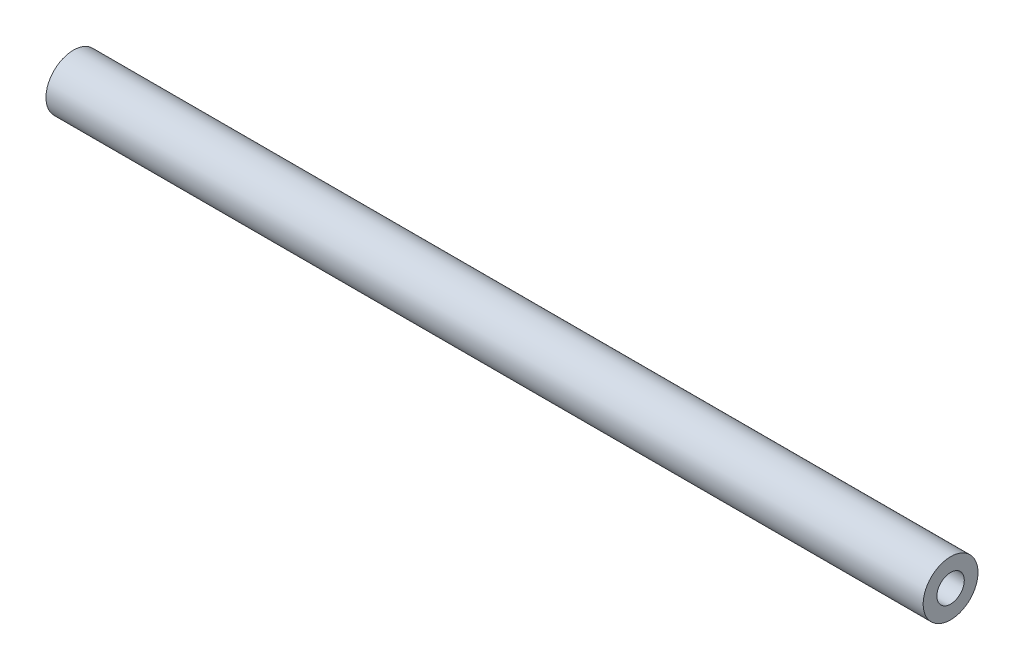
from build123d import *

# Parameters (mm, degrees)
SKETCH1_R           = 6.35
SKETCH1_R_2         = 3.175
BOSS_EXTRUDE1_DEPTH = 203.2


with BuildPart() as part:
    # Sketch1 → Boss-Extrude1 (new body)
    with BuildSketch(Plane(origin=(0, 0, 0), x_dir=(0, 0, -1), z_dir=(1, 0, 0))):
        Circle(SKETCH1_R)
        Circle(SKETCH1_R_2, mode=Mode.SUBTRACT)
    extrude(amount=BOSS_EXTRUDE1_DEPTH)


solid = part.part
